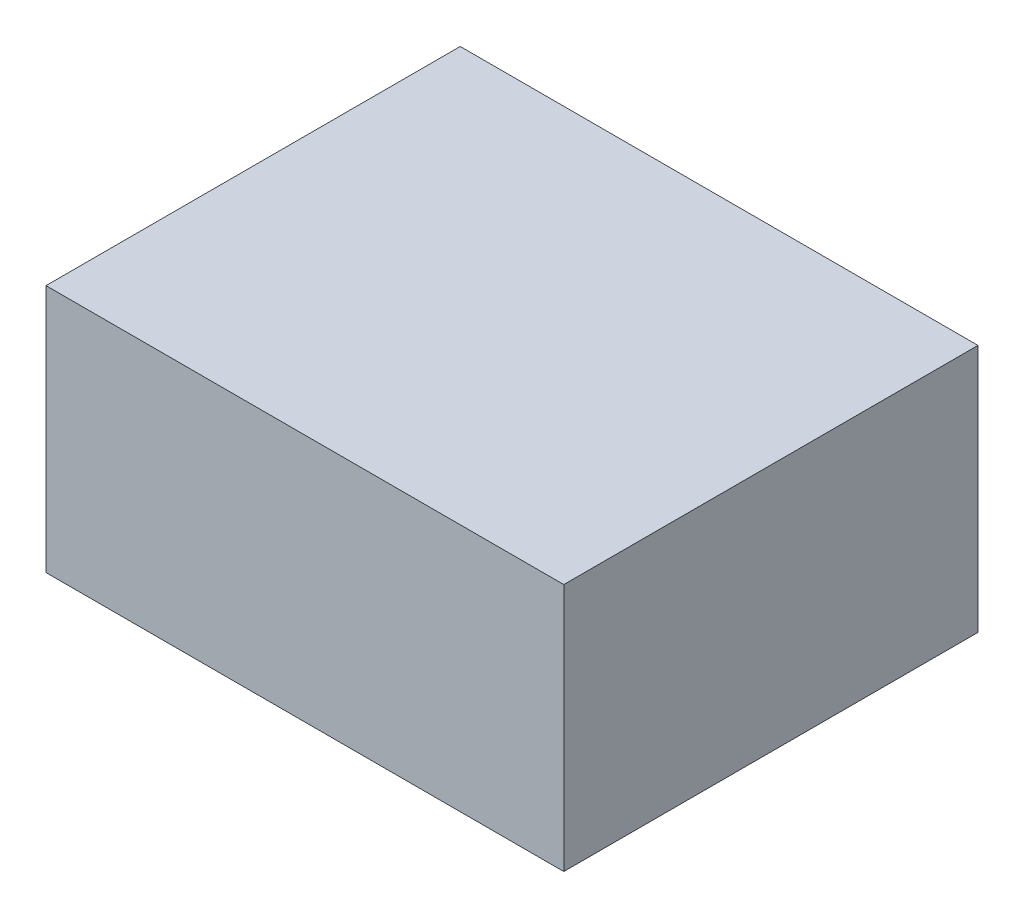
from build123d import *

# Parameters (mm, degrees)
SKETCH1_W           = 125
SKETCH1_H           = 60
BOSS_EXTRUDE1_DEPTH = 100


with BuildPart() as part:
    # Sketch1 → Boss-Extrude1 (new body)
    with BuildSketch(Plane.XY):
        with Locations((12.5, 0)):
            Rectangle(SKETCH1_W, SKETCH1_H)
    extrude(amount=BOSS_EXTRUDE1_DEPTH)


solid = part.part
